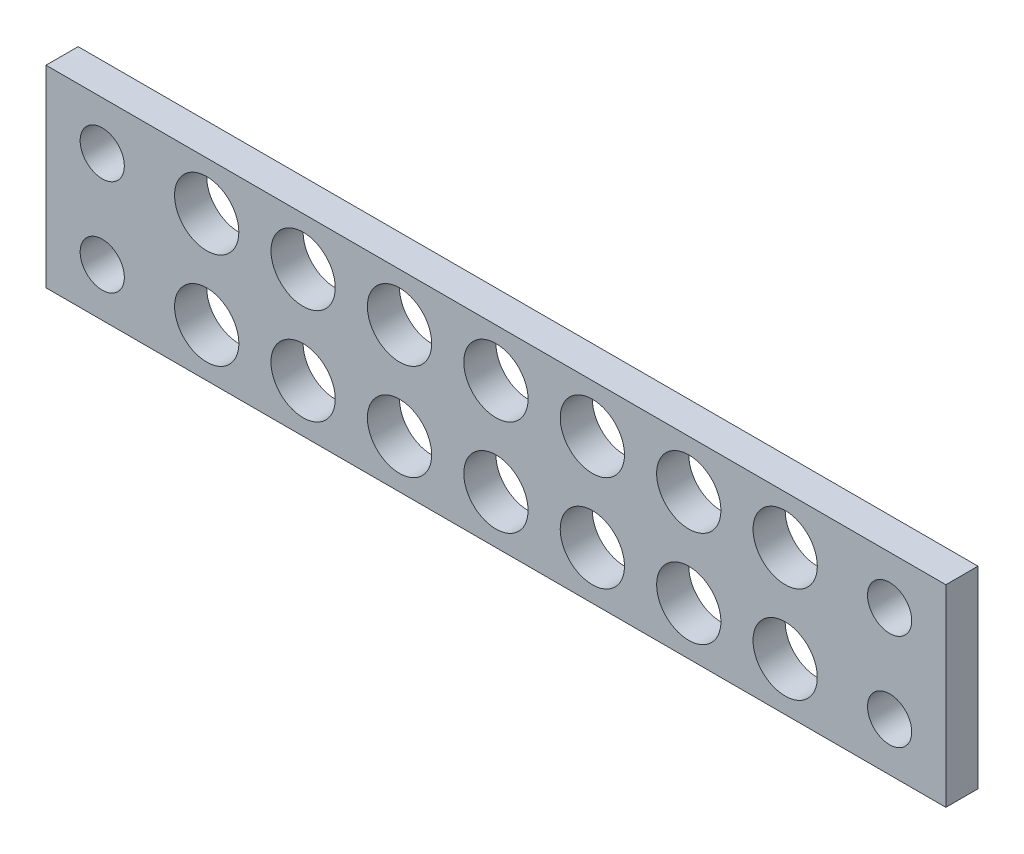
from build123d import *

# Parameters (mm, degrees)
SKETCH1_W           = 42
SKETCH1_H           = 12
TAILLIGHTBASE_DEPTH = 2
SKETCH3_W           = 7
SKETCH3_H           = 12
MOUNTINGTABS_DEPTH  = 2
SKETCH4_R           = 1.375
MOUNTINGHOLES_DEPTH = 2
SKETCH5_R           = 2
CUT_EXTRUDE1_DEPTH  = 10


with BuildPart() as part:
    # Sketch1 → tailLightBase (new body)
    with BuildSketch(Plane.XY):
        with Locations((21, 6)):
            Rectangle(SKETCH1_W, SKETCH1_H)
    extrude(amount=TAILLIGHTBASE_DEPTH)

    # Sketch3 → mountingTabs (add)
    with BuildSketch(Plane.XY.offset(2)):
        with Locations((-3.5, 6)):
            Rectangle(SKETCH3_W, SKETCH3_H)
        with Locations((45.5, 6)):
            Rectangle(SKETCH3_W, SKETCH3_H)
    extrude(amount=-MOUNTINGTABS_DEPTH)

    # Sketch4 → mountingHoles (cut)
    with BuildSketch(Plane.XY.offset(2)):
        with Locations((-3.5, 9)):
            Circle(SKETCH4_R)
        with Locations((45.5, 9)):
            Circle(SKETCH4_R)
        with Locations((-3.5, 3)):
            Circle(SKETCH4_R)
        with Locations((45.5, 3)):
            Circle(SKETCH4_R)
    extrude(amount=-MOUNTINGHOLES_DEPTH, mode=Mode.SUBTRACT)

    # Sketch5 → Cut-Extrude1 (cut)
    with BuildSketch(Plane.XY.offset(2)):
        with Locations((3, 9)):
            Circle(SKETCH5_R)
        with Locations((9, 9)):
            Circle(SKETCH5_R)
        with Locations((15, 9)):
            Circle(SKETCH5_R)
        with Locations((21, 9)):
            Circle(SKETCH5_R)
        with Locations((27, 9)):
            Circle(SKETCH5_R)
        with Locations((33, 9)):
            Circle(SKETCH5_R)
        with Locations((39, 9)):
            Circle(SKETCH5_R)
        with Locations((39, 3)):
            Circle(SKETCH5_R)
        with Locations((33, 3)):
            Circle(SKETCH5_R)
        with Locations((27, 3)):
            Circle(SKETCH5_R)
        with Locations((21, 3)):
            Circle(SKETCH5_R)
        with Locations((15, 3)):
            Circle(SKETCH5_R)
        with Locations((9, 3)):
            Circle(SKETCH5_R)
        with Locations((3, 3)):
            Circle(SKETCH5_R)
    extrude(amount=-CUT_EXTRUDE1_DEPTH, mode=Mode.SUBTRACT)


solid = part.part
